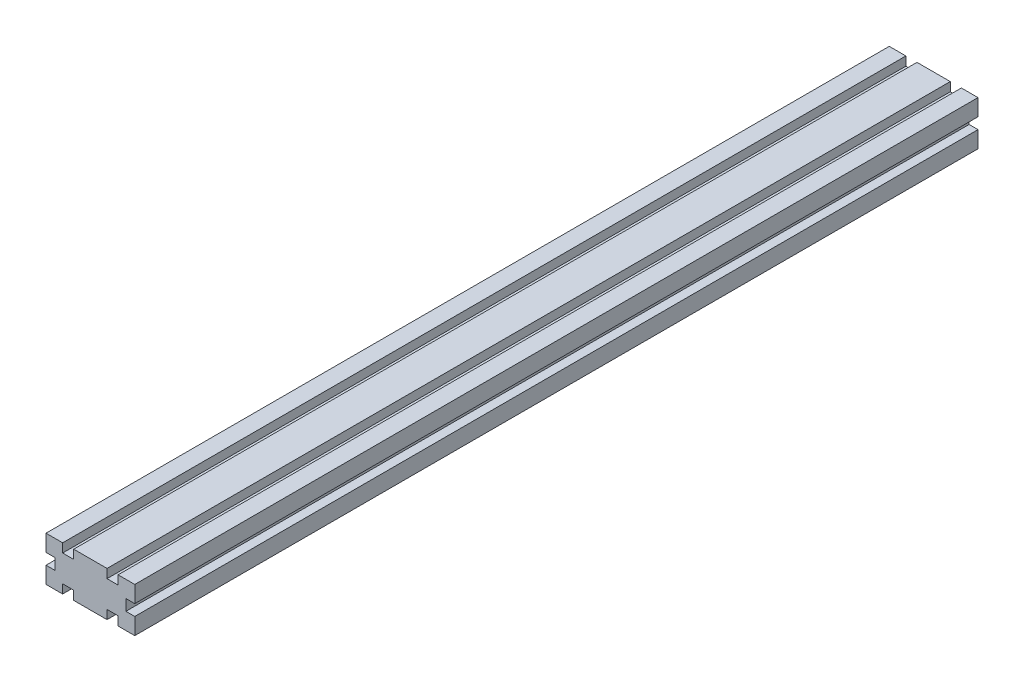
from build123d import *

# Parameters (mm, degrees)
ESQUISSE1_W        = 3.5
ESQUISSE1_H        = 5
ESQUISSE1_W_2      = 5
ESQUISSE1_H_2      = 3.5
ESQUISSE1_W_3      = 4
BOSS_EXTRU_1_DEPTH = 380


with BuildPart() as part:
    # Esquisse1 → Boss.-Extru.1 (new body)
    with BuildSketch(Plane.XY):
        Polygon((7.5, 16), (7.5, 20), (0, 20), (4, 16), align=None)
        Polygon((4, 16), (0, 20), (0, 12.5), (4, 12.5), align=None)
        Polygon((4, 7.5), (0, 7.5), (0, 0), (4, 4), align=None)
        Polygon((0, 0), (7.5, 0), (7.5, 4), (4, 4), align=None)
        Polygon((4, 4), (7.5, 7.5), (4, 7.5), align=None)
        Polygon((7.5, 4), (7.5, 7.5), (4, 4), align=None)
        Polygon((4, 12.5), (7.5, 12.5), (4, 16), align=None)
        Polygon((7.5, 12.5), (7.5, 16), (4, 16), align=None)
        with Locations((5.75, 10)):
            Rectangle(ESQUISSE1_W, ESQUISSE1_H)
        Polygon((7.5, 7.5), (10, 10), (7.5, 12.5), align=None)
        Polygon((10, 10), (12.5, 12.5), (7.5, 12.5), align=None)
        Polygon((12.5, 7.5), (12.5, 12.5), (10, 10), align=None)
        Polygon((12.5, 7.5), (10, 10), (7.5, 7.5), align=None)
        Polygon((16, 4), (12.5, 7.5), (12.5, 4), align=None)
        Polygon((16, 4), (16, 7.5), (12.5, 7.5), align=None)
        Polygon((20, 0), (20, 7.5), (16, 7.5), (16, 4), align=None)
        with Locations((10, 14.25)):
            Rectangle(ESQUISSE1_W_2, ESQUISSE1_H_2)
        with Locations((14.25, 10)):
            Rectangle(ESQUISSE1_W, ESQUISSE1_H)
        Polygon((12.5, 12.5), (16, 16), (12.5, 16), align=None)
        Polygon((16, 16), (20, 20), (12.5, 20), (12.5, 16), align=None)
        Polygon((16, 12.5), (16, 16), (12.5, 12.5), align=None)
        Polygon((20, 12.5), (20, 20), (16, 16), (16, 12.5), align=None)
        Polygon((12.5, 0), (20, 0), (16, 4), (12.5, 4), align=None)
        with Locations((10, 5.75)):
            Rectangle(ESQUISSE1_W_2, ESQUISSE1_H_2)
        with Locations((18, 10)):
            Rectangle(ESQUISSE1_W_3, ESQUISSE1_H)
        with Locations((22, 10)):
            Rectangle(ESQUISSE1_W_3, ESQUISSE1_H)
        Polygon((24, 16), (20, 20), (20, 12.5), (24, 12.5), align=None)
        Polygon((27.5, 20), (20, 20), (24, 16), (27.5, 16), align=None)
        Polygon((27.5, 12.5), (24, 16), (24, 12.5), align=None)
        Polygon((27.5, 16), (24, 16), (27.5, 12.5), align=None)
        with Locations((25.75, 10)):
            Rectangle(ESQUISSE1_W, ESQUISSE1_H)
        Polygon((27.5, 7.5), (24, 7.5), (24, 4), align=None)
        Polygon((24, 7.5), (20, 7.5), (20, 0), (24, 4), align=None)
        Polygon((24, 4), (20, 0), (27.5, 0), (27.5, 4), align=None)
        Polygon((27.5, 4), (27.5, 7.5), (24, 4), align=None)
        with Locations((30, 5.75)):
            Rectangle(ESQUISSE1_W_2, ESQUISSE1_H_2)
        Polygon((36, 4), (32.5, 7.5), (32.5, 4), align=None)
        Polygon((36, 7.5), (32.5, 7.5), (36, 4), align=None)
        Polygon((40, 0), (40, 7.5), (36, 7.5), (36, 4), align=None)
        Polygon((32.5, 4), (32.5, 0), (40, 0), (36, 4), align=None)
        with Locations((34.25, 10)):
            Rectangle(ESQUISSE1_W, ESQUISSE1_H)
        Polygon((32.5, 12.5), (30, 10), (32.5, 7.5), align=None)
        Polygon((32.5, 7.5), (30, 10), (27.5, 7.5), align=None)
        Polygon((30, 10), (27.5, 12.5), (27.5, 7.5), align=None)
        Polygon((32.5, 12.5), (27.5, 12.5), (30, 10), align=None)
        Polygon((36, 16), (32.5, 12.5), (36, 12.5), align=None)
        Polygon((36, 16), (32.5, 16), (32.5, 12.5), align=None)
        Polygon((40, 20), (32.5, 20), (32.5, 16), (36, 16), align=None)
        Polygon((40, 12.5), (40, 20), (36, 16), (36, 12.5), align=None)
        with Locations((30, 14.25)):
            Rectangle(ESQUISSE1_W_2, ESQUISSE1_H_2)
    extrude(amount=BOSS_EXTRU_1_DEPTH)


solid = part.part
